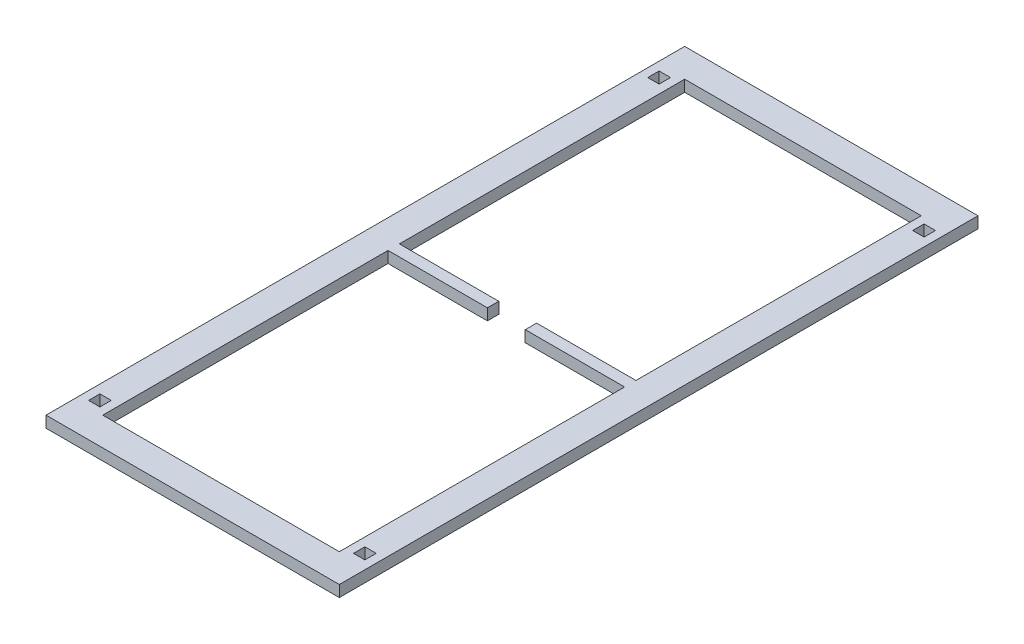
from build123d import *

# Parameters (mm, degrees)
SKETCH1_W               = 310
SKETCH1_H               = 675
SKETCH1_W_2             = 300
SKETCH1_H_2             = 665
SKETCH1_W_3             = 260
SKETCH1_H_3             = 625
SKETCH1_W_4             = 250
SKETCH1_H_4             = 615
BOSS_EXTRUDE1_DEPTH     = 12
SKETCH2_W               = 12
SKETCH2_H               = 12
CUT_EXTRUDE1_DEPTH      = 1
CUT_EXTRUDE1_DEPTH_BACK = 13
SKETCH3_W               = 105
SKETCH3_H               = 12
BOSS_EXTRUDE2_DEPTH     = 12


with BuildPart() as part:
    # Sketch1 → Boss-Extrude1 (new body)
    with BuildSketch(Plane(origin=(0, 0, 0), x_dir=(1, 0, 0), z_dir=(0, 1, 0))):
        Rectangle(SKETCH1_W, SKETCH1_H)
        Rectangle(SKETCH1_W_2, SKETCH1_H_2, mode=Mode.SUBTRACT)
        Rectangle(SKETCH1_W_2, SKETCH1_H_2)
        Rectangle(SKETCH1_W_3, SKETCH1_H_3, mode=Mode.SUBTRACT)
        Rectangle(SKETCH1_W_3, SKETCH1_H_3)
        Rectangle(SKETCH1_W_4, SKETCH1_H_4, mode=Mode.SUBTRACT)
    extrude(amount=BOSS_EXTRUDE1_DEPTH)

    # Sketch2 → Cut-Extrude1 (cut, two sides)
    with BuildSketch(Plane(origin=(0, 12, 0), x_dir=(1, 0, 0), z_dir=(0, 1, 0))) as cut_extrude1_sk:
        with Locations((-140, -295.5)):
            Rectangle(SKETCH2_W, SKETCH2_H)
        with Locations((-140, 295.5)):
            Rectangle(SKETCH2_W, SKETCH2_H)
        with Locations((140, 295.5)):
            Rectangle(SKETCH2_W, SKETCH2_H)
        with Locations((140, -295.5)):
            Rectangle(SKETCH2_W, SKETCH2_H)
    extrude(amount=CUT_EXTRUDE1_DEPTH, mode=Mode.SUBTRACT)
    extrude(cut_extrude1_sk.sketch, amount=-CUT_EXTRUDE1_DEPTH_BACK, mode=Mode.SUBTRACT)

    # Sketch3 → Boss-Extrude2 (add)
    with BuildSketch(Plane(origin=(0, 12, 0), x_dir=(1, 0, 0), z_dir=(0, 1, 0))):
        with Locations((-72.5, 0)):
            Rectangle(SKETCH3_W, SKETCH3_H)
        with Locations((72.5, 0)):
            Rectangle(SKETCH3_W, SKETCH3_H)
    extrude(amount=-BOSS_EXTRUDE2_DEPTH)


solid = part.part
